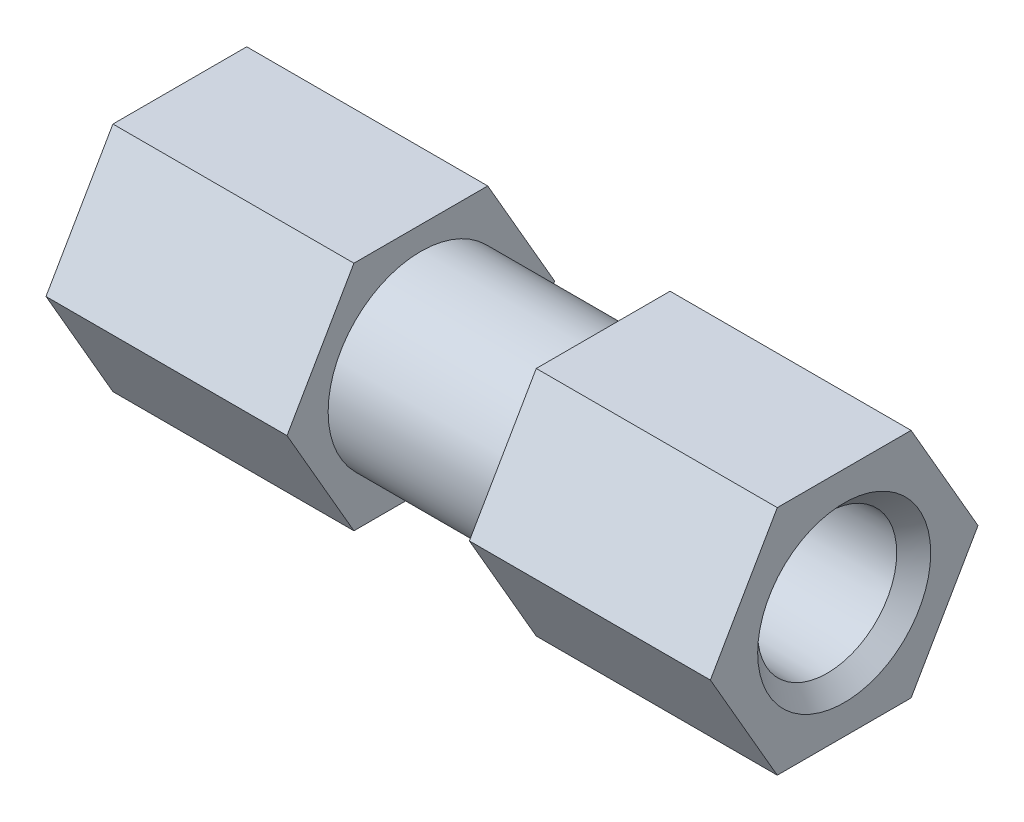
from build123d import *

# Parameters (mm, degrees)
BOSS_EXTRUDE1_DEPTH   = 19.812
SKETCH2_R             = 7.62
BOSS_EXTRUDE2_DEPTH   = 14.986
BOSS_EXTRUDE3_DEPTH   = 19.812
CHAMFER1_SIZE2        = 1.397459912
CHAMFER1_SIZE         = 1.361150227
CHAMFER1_EDGE_2_SIZE2 = 1.397459912
CHAMFER1_EDGE_2_SIZE  = 1.361150227


with BuildPart() as part:
    # Sketch1 → Boss-Extrude1 (new body)
    with BuildSketch(Plane(origin=(0, 0, 0), x_dir=(0, -1, 0), z_dir=(-1, 0, 0))):
        Polygon((-9.525, 5.499261314), (-9.525, -5.499261314), (0, -10.998522628), (9.525, -5.499261314), (9.525, 5.499261314), (0, 10.998522628), align=None)
    extrude(amount=-BOSS_EXTRUDE1_DEPTH)

    # Sketch2 → Boss-Extrude2 (add)
    with BuildSketch(Plane(origin=(19.812, 0, 0), x_dir=(0, 0, -1), z_dir=(1, 0, 0))):
        Circle(SKETCH2_R)
    extrude(amount=BOSS_EXTRUDE2_DEPTH)

    # Sketch3 → Boss-Extrude3 (add)
    with BuildSketch(Plane(origin=(34.798, 0, 0), x_dir=(0, -1, 0), z_dir=(-1, 0, 0))):
        Polygon((9.525, -5.499261314), (9.525, 5.499261314), (0, 10.998522628), (-9.525, 5.499261314), (-9.525, -5.499261314), (0, -10.998522628), align=None)
    extrude(amount=-BOSS_EXTRUDE3_DEPTH)

    # Sketch4 → Hole1 (revolve, cut)
    with BuildSketch(Plane(origin=(54.61, 0, 0), x_dir=(0, 0, -1), z_dir=(0, 1, 0))):
        Polygon((0, 0), (0, 9.906), (5.49664229, 9.906), (5.750849773, 0), align=None)
    revolve(axis=Axis((-55.39, 0, 0), (1, 0, 0)), mode=Mode.SUBTRACT)

    # Sketch6 → Hole2 (revolve, cut)
    with BuildSketch(Plane.ZX):
        Polygon((0, 0), (0, 9.906), (5.49664229, 9.906), (5.750849773, 0), align=None)
    revolve(axis=Axis((110, 0, 0), (-1, 0, 0)), mode=Mode.SUBTRACT)

    # Chamfer1
    chamfer1_edges = [part.edges().sort_by_distance(p)[0] for p in [
        (54.61, 0, 5.750849773),
    ]]
    chamfer(chamfer1_edges, length=CHAMFER1_SIZE, length2=CHAMFER1_SIZE2)

    # Chamfer1 edge 2
    chamfer1_edge_2_edges = [part.edges().sort_by_distance(p)[0] for p in [
        (0, 0, -5.750849773),
    ]]
    chamfer(chamfer1_edge_2_edges, length=CHAMFER1_EDGE_2_SIZE, length2=CHAMFER1_EDGE_2_SIZE2)


solid = part.part
